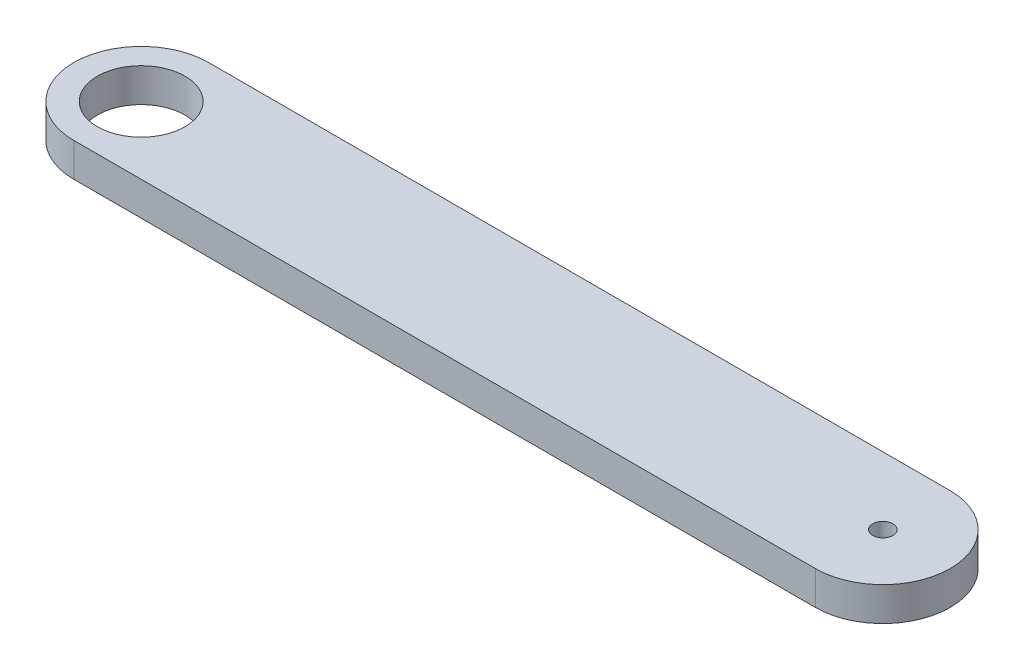
from build123d import *

# Parameters (mm, degrees)
SKETCH1_R           = 13
SKETCH1_R_2         = 3
BOSS_EXTRUDE1_DEPTH = 10


with BuildPart() as part:
    # Sketch1 → Boss-Extrude1 (new body)
    with BuildSketch(Plane(origin=(0, 0, 0), x_dir=(1, 0, 0), z_dir=(0, 1, 0))):
        with BuildLine():
            Line((220, 20), (0, 20))
            ThreePointArc((0, 20), (-20, 0), (0, -20))
            Line((0, -20), (220, -20))
            ThreePointArc((220, -20), (240, 0), (220, 20))
        make_face()
        Circle(SKETCH1_R, mode=Mode.SUBTRACT)
        with Locations((220, 0)):
            Circle(SKETCH1_R_2, mode=Mode.SUBTRACT)
    extrude(amount=BOSS_EXTRUDE1_DEPTH)


solid = part.part
